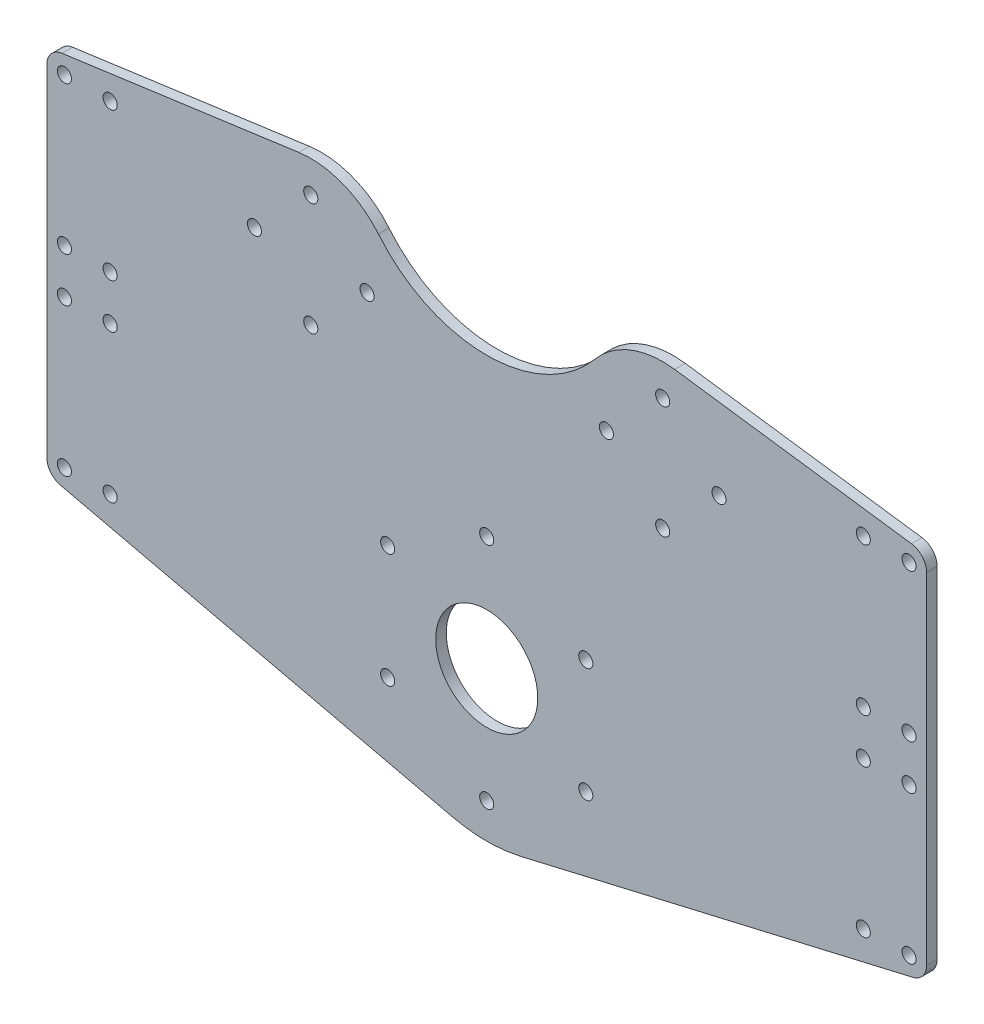
from build123d import *

# Parameters (mm, degrees)
SKETCH1_R                = 14.5
BOSS_EXTRUDE1_DEPTH      = 3
M4_CLEARANCE_HOLE1_D     = 4
M4_CLEARANCE_HOLE1_DEPTH = 10
M4_CLEARANCE_HOLE1_TIP   = 1.201721238
CIRPATTERN1_COUNT        = 6
M4_CLEARANCE_HOLE3_D     = 4


with BuildPart() as part:
    # Sketch1 → Boss-Extrude1 (new body)
    with BuildSketch(Plane.XY):
        with BuildLine():
            Line((-125, 10.558810184), (-125, -86.112499703))
            ThreePointArc((-125, -86.112499703), (-123.915997441, -89.221352232), (-121.134014383, -90.982203121))
            Line((-121.134014383, -90.982203121), (-9.639122255, -116.946168572))
            ThreePointArc((-9.639122255, -116.946168572), (0, -118.053689519), (9.639122255, -116.946168572))
            Line((9.639122255, -116.946168572), (121.134014383, -90.982203121))
            ThreePointArc((121.134014383, -90.982203121), (123.915997441, -89.221352232), (125, -86.112499703))
            Line((125, -86.112499703), (125, 10.558810184))
            ThreePointArc((125, 10.558810184), (123.768755522, 13.844610211), (120.681407274, 15.512160982))
            Line((120.681407274, 15.512160982), (53.407036368, 24.76675399))
            ThreePointArc((53.407036368, 24.76675399), (40.948782136, 23.303979385), (30.769230769, 15.974276659))
            ThreePointArc((30.769230769, 15.974276659), (0, 1.533119315), (-30.769230769, 15.974276659))
            ThreePointArc((-30.769230769, 15.974276659), (-40.948782136, 23.303979385), (-53.407036368, 24.76675399))
            Line((-53.407036368, 24.76675399), (-120.681407274, 15.512160982))
            ThreePointArc((-120.681407274, 15.512160982), (-123.768755522, 13.844610211), (-125, 10.558810184))
        make_face()
        with Locations((0, -75.553689519)):
            Circle(SKETCH1_R, mode=Mode.SUBTRACT)
    extrude(amount=BOSS_EXTRUDE1_DEPTH)

    # M4 Clearance Hole1
    with Locations(Plane.XY.offset(3)):
        with Locations((-66, 0), (-34, 0), (-50, 16), (-50, -16), (34, 0), (50, 16), (66, 0), (50, -16)):
            Hole(M4_CLEARANCE_HOLE1_D / 2, depth=M4_CLEARANCE_HOLE1_DEPTH)
            with Locations((0, 0, -(M4_CLEARANCE_HOLE1_DEPTH + M4_CLEARANCE_HOLE1_TIP / 2))):  # 118° drill point
                Cone(0, M4_CLEARANCE_HOLE1_D / 2, M4_CLEARANCE_HOLE1_TIP, mode=Mode.SUBTRACT)

    # Sketch8 → M4 Clearance Hole2 (revolve, cut)
    with BuildSketch(Plane(origin=(0, -108.053689519, 3), x_dir=(0, -1, 0), z_dir=(1, 0, 0))):
        Polygon((0, 0), (0, 11.201721238), (2, 10), (2, 0), align=None)
    m4_clearance_hole2 = revolve(axis=Axis((0, -108.053689519, 9.35), (0, 0, -1)), mode=Mode.SUBTRACT)

    # CirPattern1: M4 Clearance Hole2 ×6 about axis
    cirpattern1_axis = Axis((0, -75.553689519, 0), (0, 0, 1))
    for i in range(1, CIRPATTERN1_COUNT):
        add(m4_clearance_hole2.rotate(cirpattern1_axis, i * 360 / CIRPATTERN1_COUNT), mode=Mode.SUBTRACT)

    # M4 Clearance Hole3 (through all)
    with Locations(Plane.XY.offset(3)):
        with Locations((-120, 10.558810184), (-107, 10.558810184), (-120, -31.441189816), (-107, -31.441189816), (-120, -86.112499703), (-107, -44.112499703), (-120, -44.112499703), (-107, -86.112499703), (120, 10.558810184), (107, -31.441189816), (120, -31.441189816), (107, 10.558810184), (120, -86.112499703), (107, -44.112499703), (120, -44.112499703), (107, -86.112499703)):
            Hole(M4_CLEARANCE_HOLE3_D / 2)


solid = part.part
